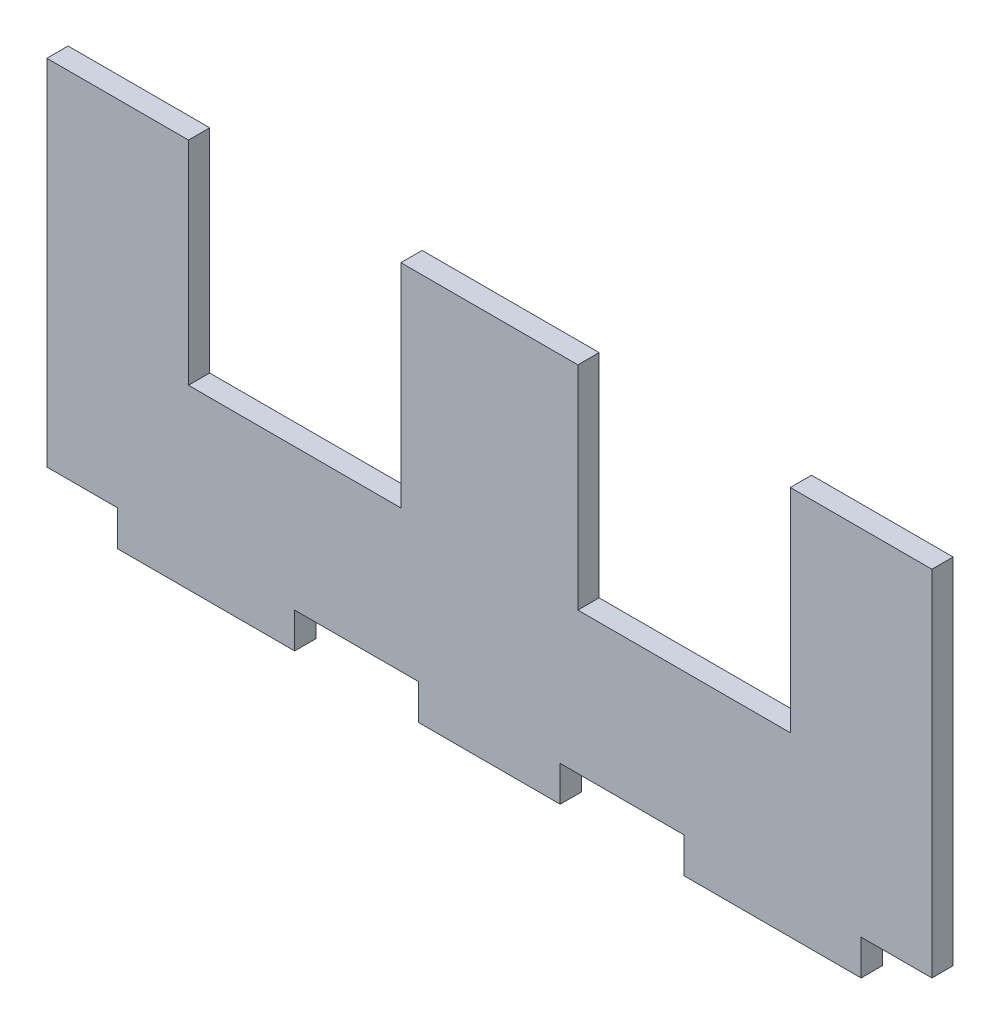
from build123d import *

# Parameters (mm, degrees)
RESSALTO_EXTRUS_O1_DEPTH = 3
ESBO_O2_W                = 30
ESBO_O2_H                = 30
CORTE_EXTRUS_O1_DEPTH    = 4


with BuildPart() as part:
    # Esboço1 → Ressalto-extrusão1 (new body)
    with BuildSketch(Plane.XY):
        Polygon((-38.490777312, -22.896341463), (-20.990777312, -22.896341463), (-20.990777312, -27.896341463), (-0.990777312, -27.896341463), (-0.990777312, -22.896341463), (16.509222688, -22.896341463), (16.509222688, -27.896341463), (41.509222688, -27.896341463), (41.509222688, -22.896341463), (51.509222688, -22.896341463), (51.509222688, 27.103658537), (-73.490777312, 27.103658537), (-73.490777312, -22.896341463), (-63.490777312, -22.896341463), (-63.490777312, -27.896341463), (-38.490777312, -27.896341463), align=None)
    extrude(amount=RESSALTO_EXTRUS_O1_DEPTH)

    # Esboço2 → Corte-extrusão1 (cut, through all)
    with BuildSketch(Plane(origin=(0, 0, 0), x_dir=(-1, 0, 0), z_dir=(0, 0, -1))):
        with Locations((-16.509222688, 12.103658537)):
            Rectangle(ESBO_O2_W, ESBO_O2_H)
        with Locations((38.490777312, 12.103658537)):
            Rectangle(ESBO_O2_W, ESBO_O2_H)
    extrude(amount=-CORTE_EXTRUS_O1_DEPTH, mode=Mode.SUBTRACT)


solid = part.part
